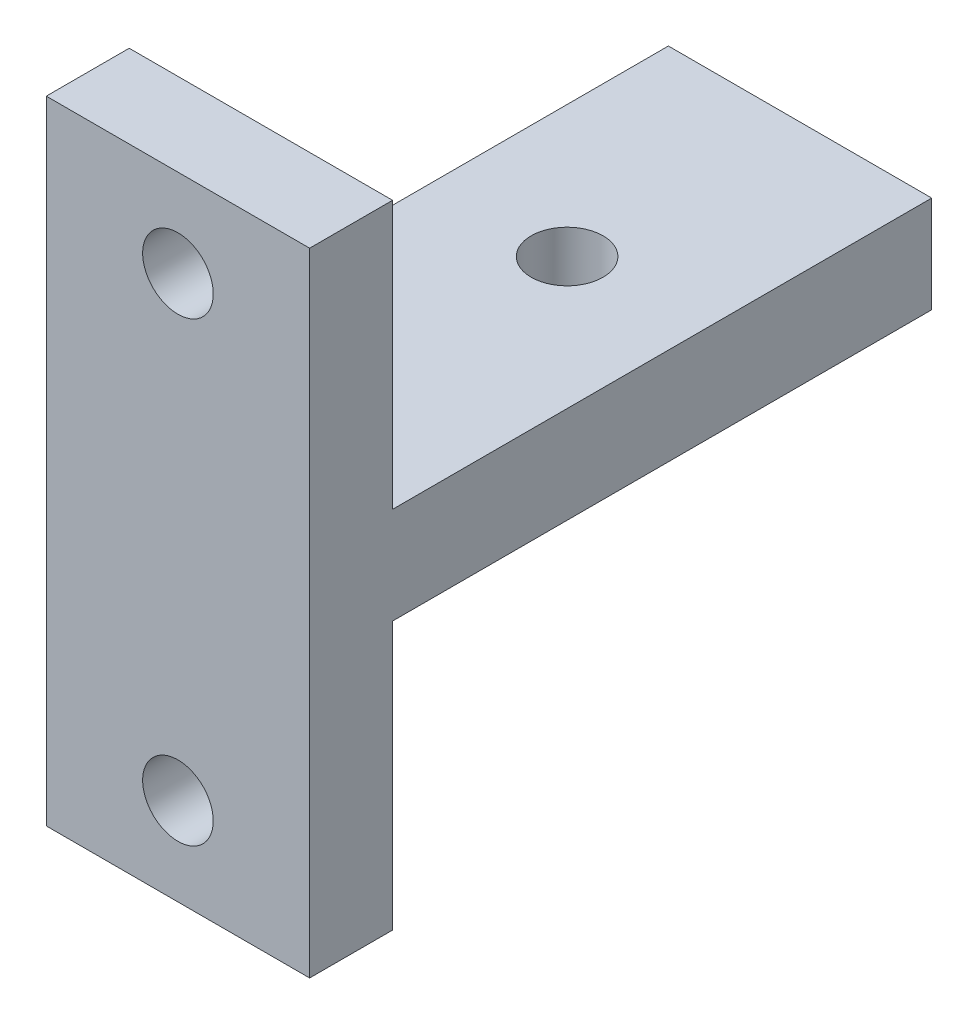
from build123d import *

# Parameters (mm, degrees)
SKETCH1_W           = 19.05
SKETCH1_H           = 19.36
SKETCH1_R           = 2.5527
SKETCH1_H_2         = 7
BOSS_EXTRUDE1_DEPTH = 6
SKETCH3_W           = 19.05
SKETCH3_H           = 7
BOSS_EXTRUDE2_DEPTH = 45
SKETCH4_R           = 2.6
CUT_EXTRUDE1_DEPTH  = 27.36


with BuildPart() as part:
    # Sketch1 → Boss-Extrude1 (new body)
    with BuildSketch(Plane.XY):
        with Locations((0, 13.18)):
            Rectangle(SKETCH1_W, SKETCH1_H)
        with Locations((0, 16.51)):
            Circle(SKETCH1_R, mode=Mode.SUBTRACT)
        with Locations((0, -13.18)):
            Rectangle(SKETCH1_W, SKETCH1_H)
        with Locations((0, -16.51)):
            Circle(SKETCH1_R, mode=Mode.SUBTRACT)
        Rectangle(SKETCH1_W, SKETCH1_H_2)
    extrude(amount=-BOSS_EXTRUDE1_DEPTH)

    # Sketch3 → Boss-Extrude2 (add)
    with BuildSketch(Plane.XY):
        Rectangle(SKETCH3_W, SKETCH3_H)
    extrude(amount=-BOSS_EXTRUDE2_DEPTH)

    # Sketch4 → Cut-Extrude1 (cut, through all)
    with BuildSketch(Plane(origin=(0, 3.5, 0), x_dir=(1, 0, 0), z_dir=(0, 1, 0))):
        with Locations((0, 28.15)):
            Circle(SKETCH4_R)
    extrude(amount=-CUT_EXTRUDE1_DEPTH, mode=Mode.SUBTRACT)


solid = part.part
